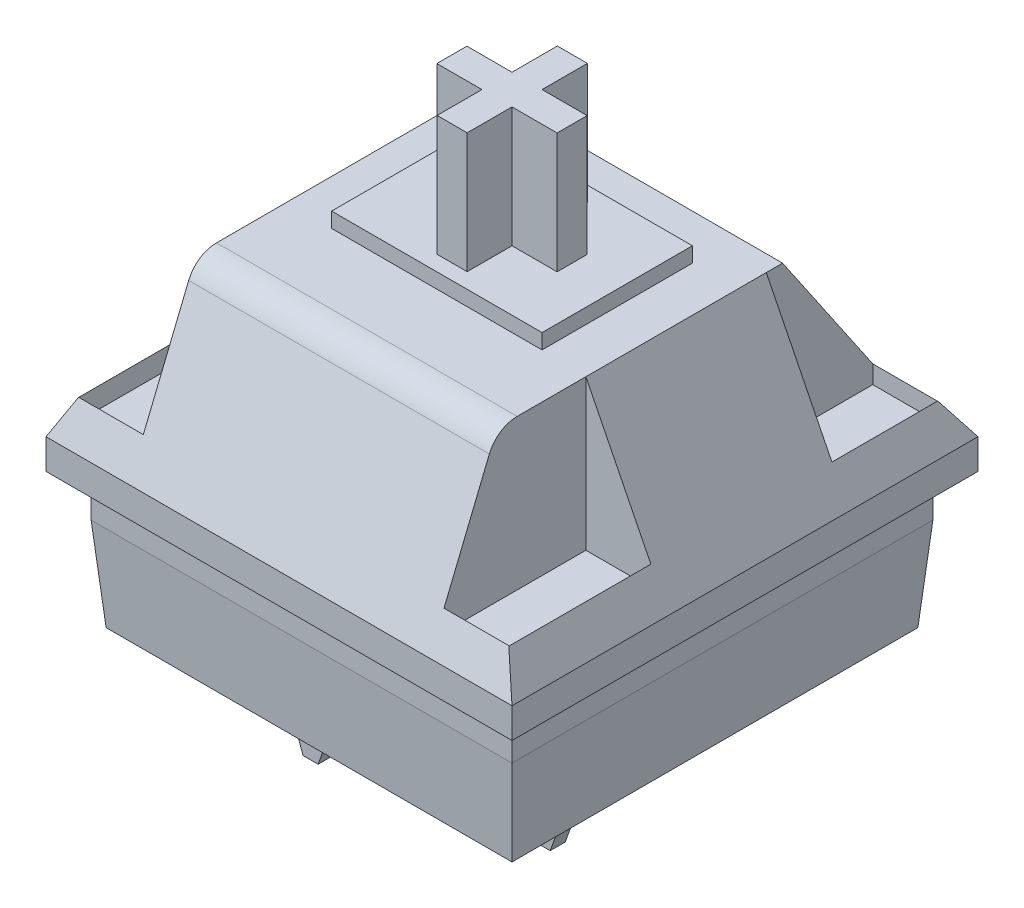
from build123d import *

# Parameters (mm, degrees)
SKETCH_2_W           = 14
SKETCH_2_H           = 14
EXTRUDE_1_DEPTH      = 1.4
SKETCH_1_W           = 13.5
SKETCH_1_H           = 13.5
SKETCH_8_W           = 15.5
SKETCH_8_H           = 15.5
EXTRUDE_2_DEPTH      = 1
SKETCH_10_W          = 10
SKETCH_10_H          = 9.5
SKETCH_12_W          = 7
SKETCH_12_H          = 5
EXTRUDE_3_DEPTH      = 0.5
EXTRUDE_5_DEPTH      = 4
SKETCH_16_R          = 2
EXTRUDE_6_DEPTH      = 3
CHAMFER_1_SIZE       = 0.25
CHAMFER_1_SIZE2      = 0.686869355
SKETCH_18_W          = 8
SKETCH_18_H          = 3
CUT_EXTRUDE_1_DEPTH  = 4.5
SKETCH_20_W          = 2.183812488
SKETCH_20_H          = 3.542412762
CUT_EXTRUDE_9_DEPTH  = 5
SKETCH_23_W          = 2.16
SKETCH_23_H          = 4.720066995
CUT_EXTRUDE_10_DEPTH = 5
SKETCH_26_R          = 1.5
CUT_EXTRUDE_12_DEPTH = 5.5
SKETCH_27_W          = 1
SKETCH_27_H          = 0.5
EXTRUDE_7_DEPTH      = 3
CHAMFER_2_SIZE       = 0.25
CHAMFER_2_SIZE2      = 0.686869355
CHAMFER_3_SIZE       = 0.25
CHAMFER_3_SIZE2      = 0.686869355
FILLET_1_R           = 1


with BuildPart() as part:
    # 草图2 → 凸台-拉伸1 (new body)
    with BuildSketch(Plane(origin=(0, 4.5, 0), x_dir=(1, 0, 0), z_dir=(0, 1, 0))):
        Rectangle(SKETCH_2_W, SKETCH_2_H)
    extrude(amount=-EXTRUDE_1_DEPTH)

    # 草图1 → section 1 of loft_2
    with BuildSketch(Plane(origin=(0, 0, 0), x_dir=(1, 0, 0), z_dir=(0, 1, 0)), mode=Mode.PRIVATE) as loft_2_s1:
        Rectangle(SKETCH_1_W, SKETCH_1_H)
    # loft from a face of the part (loft_2)
    loft([part.faces().sort_by_distance((0, 3.1, 0))[0], loft_2_s1.sketch])

    # 草图8 → 凸台-拉伸2 (add)
    with BuildSketch(Plane(origin=(0, 4.5, 0), x_dir=(1, 0, 0), z_dir=(0, 1, 0))):
        Rectangle(SKETCH_8_W, SKETCH_8_H)
    extrude(amount=EXTRUDE_2_DEPTH)

    # 草图10 → section 1 of loft_6
    with BuildSketch(Plane(origin=(0, 11, 0), x_dir=(1, 0, 0), z_dir=(0, 1, 0)), mode=Mode.PRIVATE) as loft_6_s1:
        with Locations((0, -0.75)):
            Rectangle(SKETCH_10_W, SKETCH_10_H)
    # loft from a face of the part (loft_6)
    loft([part.faces().sort_by_distance((0, 5.5, 0))[0], loft_6_s1.sketch])

    # 草图12 → 凸台-拉伸3 (add)
    with BuildSketch(Plane(origin=(0, 11, 0), x_dir=(1, 0, 0), z_dir=(0, 1, 0))):
        Rectangle(SKETCH_12_W, SKETCH_12_H)
    extrude(amount=EXTRUDE_3_DEPTH)

    # 草图14 → 凸台-拉伸5 (add)
    with BuildSketch(Plane(origin=(0, 11.5, 0), x_dir=(1, 0, 0), z_dir=(0, 1, 0))):
        Polygon((0.5, -0.5), (2, -0.5), (2, 0.5), (0.5, 0.5), (0.5, 2.008619841), (-0.5, 2.008619841), (-0.5, 0.5), (-2, 0.5), (-2, -0.5), (-0.5, -0.5), (-0.5, -1.991380159), (0.5, -1.991380159), align=None)
    extrude(amount=EXTRUDE_5_DEPTH)

    # 草图16 → 凸台-拉伸6 (add)
    with BuildSketch(Plane(origin=(0, 0, 0), x_dir=(-1, 0, 0), z_dir=(0, -1, 0))):
        Circle(SKETCH_16_R)
    extrude(amount=EXTRUDE_6_DEPTH)

    # 倒角1
    chamfer_1_edges = [part.edges().sort_by_distance(p)[0] for p in [
        (2, -3, 0),
    ]]
    chamfer_1_side = [part.faces().sort_by_distance(p)[0] for p in [
        (0, -3, 0),
    ]]
    chamfer(chamfer_1_edges, length=CHAMFER_1_SIZE, length2=CHAMFER_1_SIZE2, reference=chamfer_1_side[0])

    # 草图18 → 切除-拉伸1 (cut)
    with BuildSketch(Plane(origin=(0, 11, 0), x_dir=(1, 0, 0), z_dir=(0, 1, 0))):
        with Locations((0, 5.5)):
            Rectangle(SKETCH_18_W, SKETCH_18_H)
    extrude(amount=-CUT_EXTRUDE_1_DEPTH, mode=Mode.SUBTRACT)

    # 草图20 → 切除-拉伸9 (cut)
    with BuildSketch(Plane(origin=(0, 11, 0), x_dir=(1, 0, 0), z_dir=(0, 1, 0))):
        with Locations((6.091906244, 5.228793619)):
            Rectangle(SKETCH_20_W, SKETCH_20_H)
        with Locations((-6.091906244, 5.228793619)):
            Rectangle(SKETCH_20_W, SKETCH_20_H)
    extrude(amount=-CUT_EXTRUDE_9_DEPTH, mode=Mode.SUBTRACT)

    # 草图23 → 切除-拉伸10 (cut)
    with BuildSketch(Plane(origin=(0, 11, 0), x_dir=(1, 0, 0), z_dir=(0, 1, 0))):
        with Locations((6.08, -4.90244626)):
            Rectangle(SKETCH_23_W, SKETCH_23_H)
        with Locations((-6.08, -4.90244626)):
            Rectangle(SKETCH_23_W, SKETCH_23_H)
    extrude(amount=-CUT_EXTRUDE_10_DEPTH, mode=Mode.SUBTRACT)

    # 草图26 → 切除-拉伸12 (cut)
    with BuildSketch(Plane(origin=(0, 11, 0), x_dir=(1, 0, 0), z_dir=(0, 1, 0))):
        with Locations((0, 5.526038024)):
            Circle(SKETCH_26_R)
    extrude(amount=-CUT_EXTRUDE_12_DEPTH, mode=Mode.SUBTRACT)

    # 草图27 → 凸台-拉伸7 (add)
    with BuildSketch(Plane(origin=(0, 0, 0), x_dir=(1, 0, 0), z_dir=(0, 1, 0))):
        with Locations((-2.54, -3.91)):
            Rectangle(SKETCH_27_W, SKETCH_27_H)
        with Locations((3.81, -2.54)):
            Rectangle(SKETCH_27_W, SKETCH_27_H)
    extrude(amount=-EXTRUDE_7_DEPTH)

    # 倒角2
    chamfer_2_edges = [part.edges().sort_by_distance(p)[0] for p in [
        (4.31, -3, 2.54),
        (3.31, -3, 2.54),
    ]]
    chamfer_2_side = [part.faces().sort_by_distance(p)[0] for p in [
        (3.81, -3, 2.54),
    ]]
    chamfer(chamfer_2_edges, length=CHAMFER_2_SIZE, length2=CHAMFER_2_SIZE2, reference=chamfer_2_side[0])

    # 倒角3
    chamfer_3_edges = [part.edges().sort_by_distance(p)[0] for p in [
        (-2.04, -3, 3.91),
        (-3.04, -3, 3.91),
    ]]
    chamfer_3_side = [part.faces().sort_by_distance(p)[0] for p in [
        (-2.54, -3, 3.91),
    ]]
    chamfer(chamfer_3_edges, length=CHAMFER_3_SIZE, length2=CHAMFER_3_SIZE2, reference=chamfer_3_side[0])

    # 圆角1
    fillet_1_edges = [part.edges().sort_by_distance(p)[0] for p in [
        (0, 11, 5.5),
    ]]
    fillet(fillet_1_edges, radius=FILLET_1_R)


solid = part.part
